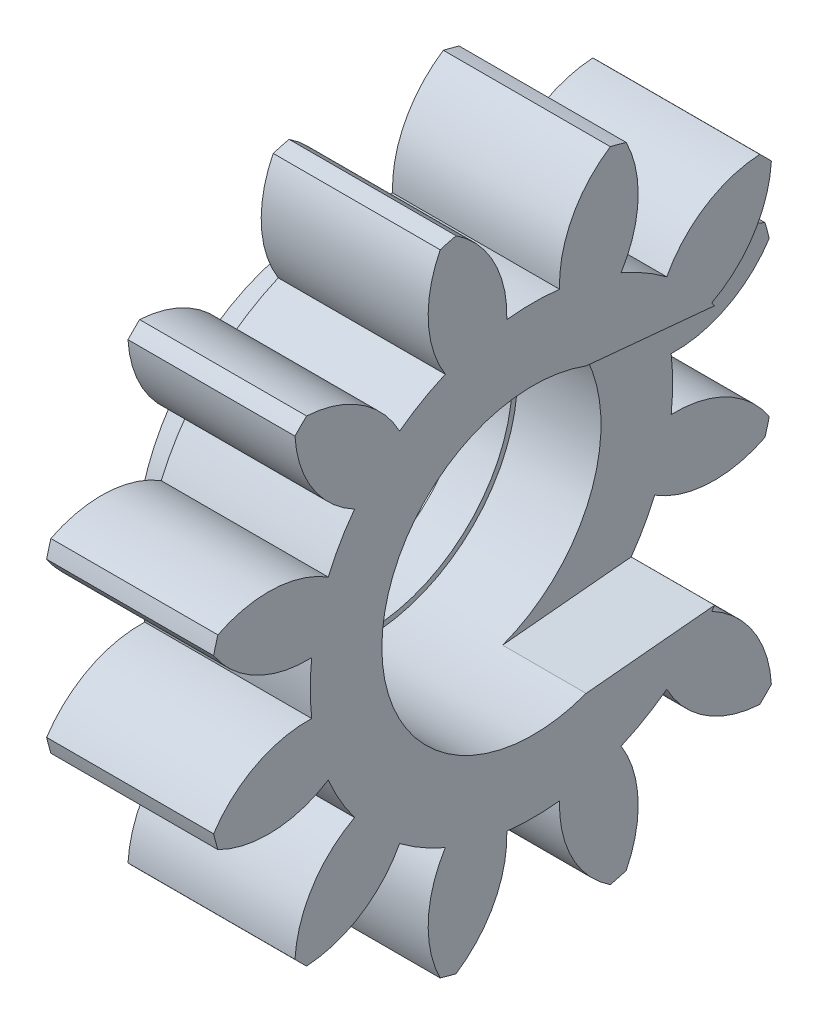
from build123d import *

# Parameters (mm, degrees)
BASPROSKE_W         = 4
BASPROSKE_H         = 7.875
TOOTHCUT_DEPTH      = 12.833480046
TEETHCUTS_COUNT     = 12
TEETHCUTS_ANGLE     = 330
BORSKE_R            = 3.625
BORE_DEPTH          = 50.0000508
SKETCH1_R           = 4.5
SKETCH1_R_2         = 3.5
BOSS_EXTRUDE1_DEPTH = 1
CUT_EXTRUDE2_DEPTH  = 2


with BuildPart() as part:
    # BasProSke → Base-Revolve (revolve)
    with BuildSketch(Plane(origin=(0, 0, 0), x_dir=(1, 0, 0), z_dir=(0, 1, 0)), mode=Mode.PRIVATE) as base_revolve_sk:
        with Locations((2, 3.9375)):
            Rectangle(BASPROSKE_W, BASPROSKE_H)
    revolve(base_revolve_sk.sketch.rotate(Axis((-10, 0, 0), (1, 0, 0)), 180), axis=Axis((-10, 0, 0), (1, 0, 0)))

    # TooCutSke → ToothCut (cut, through all)
    with BuildSketch(Plane(origin=(0, 0, 0), x_dir=(0, 0, -1), z_dir=(1, 0, 0))):
        with BuildLine():
            ThreePointArc((0.631439839, 5.305305014), (0, 5.34275), (-0.631439839, 5.305305014))
            ThreePointArc((-0.631439839, 5.305305014), (-0.93992237, 6.654932089), (-1.876748184, 7.674251521))
            ThreePointArc((-1.876748184, 7.674251521), (0, 7.9004), (1.876748184, 7.674251521))
            ThreePointArc((1.876748184, 7.674251521), (0.93992237, 6.654932089), (0.631439839, 5.305305014))
        make_face()
    toothcut = extrude(amount=TOOTHCUT_DEPTH, mode=Mode.SUBTRACT)

    # TeethCuts: ToothCut ×12 about axis
    teethcuts_axis = Axis((-10, 0, 0), (1, 0, 0))
    for i in range(1, TEETHCUTS_COUNT):
        add(toothcut.rotate(teethcuts_axis, i * TEETHCUTS_ANGLE / (TEETHCUTS_COUNT - 1)), mode=Mode.SUBTRACT)

    # BorSke → Bore (cut, symmetric)
    with BuildSketch(Plane(origin=(0, 0, 0), x_dir=(0, 0, -1), z_dir=(1, 0, 0))):
        with Locations(Location((0, 0, 0), (0, 0, 180))):
            Circle(BORSKE_R)
    extrude(amount=BORE_DEPTH, both=True, mode=Mode.SUBTRACT)

    # Sketch1 → Boss-Extrude1 (add)
    with BuildSketch(Plane.ZY):
        with Locations(Location((0, 0, 0), (0, 0, 180))):
            Circle(SKETCH1_R)
        Circle(SKETCH1_R_2, mode=Mode.SUBTRACT)
    extrude(amount=BOSS_EXTRUDE1_DEPTH)

    # Sketch3 → Cut-Extrude2 (cut)
    with BuildSketch(Plane(origin=(4, 0, 0), x_dir=(0, 0, -1), z_dir=(1, 0, 0))):
        with BuildLine():
            Line((0.328125, 3.484585195), (16.1875, 1.99119154))
            ThreePointArc((16.1875, 1.99119154), (18, 0), (16.1875, -1.99119154))
            Line((16.1875, -1.99119154), (0.328125, -3.484585195))
            ThreePointArc((0.328125, -3.484585195), (-3.5, 0), (0.328125, 3.484585195))
        make_face()
    extrude(amount=-CUT_EXTRUDE2_DEPTH, mode=Mode.SUBTRACT)


solid = part.part
